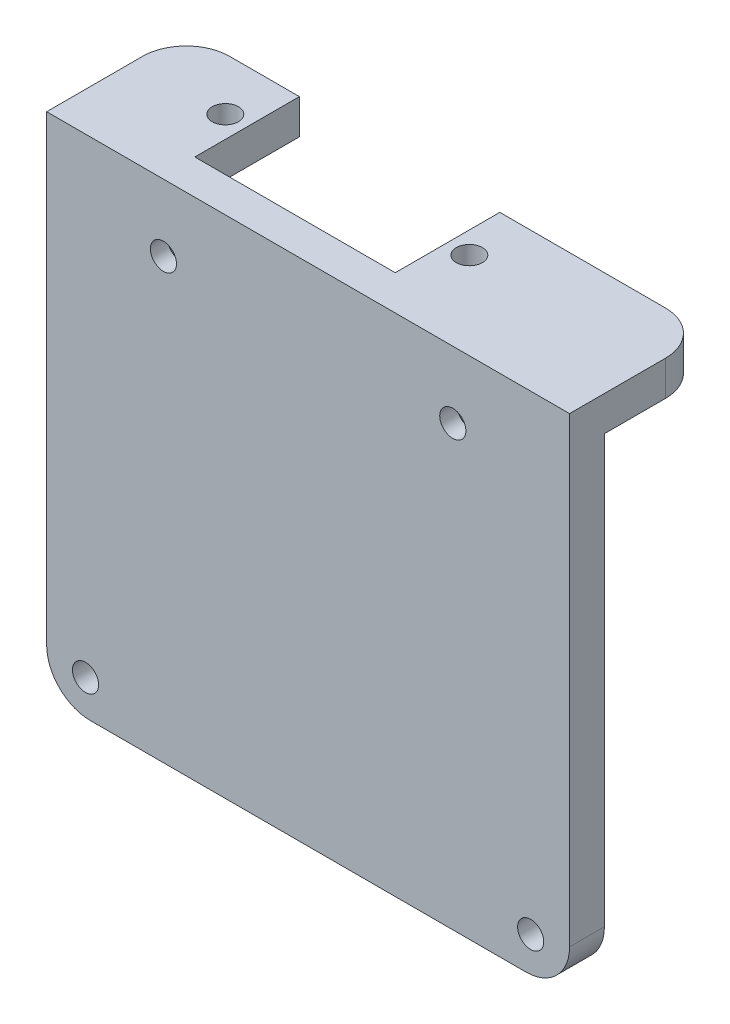
from build123d import *

# Parameters (mm, degrees)
BOSS_EXTRU_1_DEPTH      = 4
ESQUISSE2_R             = 1.5
ENL_V_MAT_EXTRU_1_DEPTH = 4
ESQUISSE3_W             = 5
ESQUISSE3_H             = 4
BOSS_EXTRU_2_DEPTH      = 12
BOSS_EXTRU_3_DEPTH      = 4
ESQUISSE5_R             = 1.5
ENL_V_MAT_EXTRU_2_DEPTH = 4
CHANFREIN2_SIZE         = 2
ESQUISSE6_W             = 20
ESQUISSE6_H             = 5
BOSS_EXTRU_4_DEPTH      = 10
CONG_1_R                = 5
ESQUISSE7_R             = 1.5
ENL_V_MAT_EXTRU_3_DEPTH = 10


with BuildPart() as part:
    # Esquisse1 → Boss.-Extru.1 (new body)
    with BuildSketch(Plane.XY):
        with BuildLine():
            Line((0, 0), (0, -53))
            ThreePointArc((0, -53), (1.464466094, -56.535533906), (5, -58))
            Line((5, -58), (55, -58))
            ThreePointArc((55, -58), (58.535533906, -56.535533906), (60, -53))
            Line((60, -53), (60, 0))
            Line((60, 0), (0, 0))
        make_face()
    extrude(amount=BOSS_EXTRU_1_DEPTH)

    # Esquisse2 → Enlèv. mat.-Extru.1 (cut)
    with BuildSketch(Plane.XY.offset(4)):
        with Locations((13.397040157, -7.66880337)):
            Circle(ESQUISSE2_R)
        with Locations((4.459764877, -53.98621161)):
            Circle(ESQUISSE2_R)
        with Locations((55.540235123, -53.98621161)):
            Circle(ESQUISSE2_R)
        with Locations((46.602959843, -7.66880337)):
            Circle(ESQUISSE2_R)
    extrude(amount=-ENL_V_MAT_EXTRU_1_DEPTH, mode=Mode.SUBTRACT)

    # Esquisse3 → Boss.-Extru.2 (add)
    with BuildSketch(Plane(origin=(0, 0, 0), x_dir=(-1, 0, 0), z_dir=(0, 0, -1))):
        with Locations((-38.5, -2)):
            Rectangle(ESQUISSE3_W, ESQUISSE3_H)
        with Locations((-10.5, -2)):
            Rectangle(ESQUISSE3_W, ESQUISSE3_H)
    extrude(amount=BOSS_EXTRU_2_DEPTH)

    # Esquisse4 → Boss.-Extru.3 (add)
    with BuildSketch(Plane(origin=(0, 0, 0), x_dir=(1, 0, 0), z_dir=(0, 1, 0))):
        with BuildLine():
            Line((0, 0), (8, 0))
            Line((8, 0), (8, 12))
            Line((8, 12), (5, 12))
            ThreePointArc((5, 12), (1.464466094, 10.535533906), (0, 7))
            Line((0, 7), (0, 0))
        make_face()
        with BuildLine():
            Line((60, 0), (41, 0))
            Line((41, 0), (41, 12))
            Line((41, 12), (55, 12))
            ThreePointArc((55, 12), (58.535533906, 10.535533906), (60, 7))
            Line((60, 7), (60, 0))
        make_face()
    extrude(amount=-BOSS_EXTRU_3_DEPTH)

    # Esquisse5 → Enlèv. mat.-Extru.2 (cut)
    with BuildSketch(Plane(origin=(0, 0, 0), x_dir=(1, 0, 0), z_dir=(0, 1, 0))):
        with Locations((10.5, 6)):
            Circle(ESQUISSE5_R)
        with Locations((38.5, 6)):
            Circle(ESQUISSE5_R)
    extrude(amount=-ENL_V_MAT_EXTRU_2_DEPTH, mode=Mode.SUBTRACT)

    # Chanfrein2
    chanfrein2_edges = [part.edges().sort_by_distance(p)[0] for p in [
        (45.102959843, -7.66880337, 0),
        (11.897040157, -7.66880337, 0),
    ]]
    chamfer(chanfrein2_edges, length=CHANFREIN2_SIZE)

    # Esquisse6 → Boss.-Extru.4 (add)
    with BuildSketch(Plane(origin=(0, 0, 0), x_dir=(-1, 0, 0), z_dir=(0, 0, -1))):
        with Locations((-29.497744904, -55.5)):
            Rectangle(ESQUISSE6_W, ESQUISSE6_H)
    extrude(amount=BOSS_EXTRU_4_DEPTH)

    # Congé1
    cong_1_edges = [part.edges().sort_by_distance(p)[0] for p in [
        (39.497744904, -55.5, -10),
        (19.497744904, -55.5, -10),
    ]]
    fillet(cong_1_edges, radius=CONG_1_R)

    # Esquisse7 → Enlèv. mat.-Extru.3 (cut)
    with BuildSketch(Plane.XZ.offset(58)):
        with Locations((29.497744904, -5)):
            Circle(ESQUISSE7_R)
    extrude(amount=-ENL_V_MAT_EXTRU_3_DEPTH, mode=Mode.SUBTRACT)


solid = part.part
